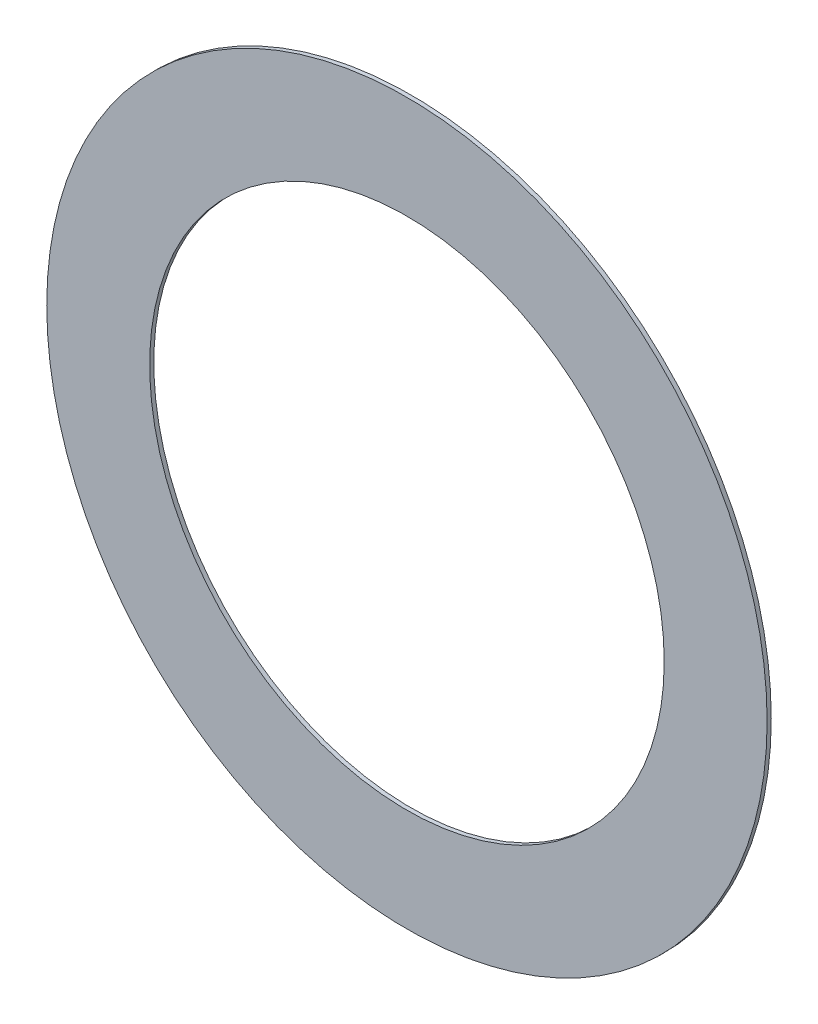
from build123d import *

# Parameters (mm, degrees)
SKETCH1_R           = 22.225
SKETCH1_R_2         = 15.875
BOSS_EXTRUDE1_DEPTH = 0.254


with BuildPart() as part:
    # Sketch1 → Boss-Extrude1 (new body)
    with BuildSketch(Plane.XY):
        Circle(SKETCH1_R)
        Circle(SKETCH1_R_2, mode=Mode.SUBTRACT)
    extrude(amount=BOSS_EXTRUDE1_DEPTH)


solid = part.part
